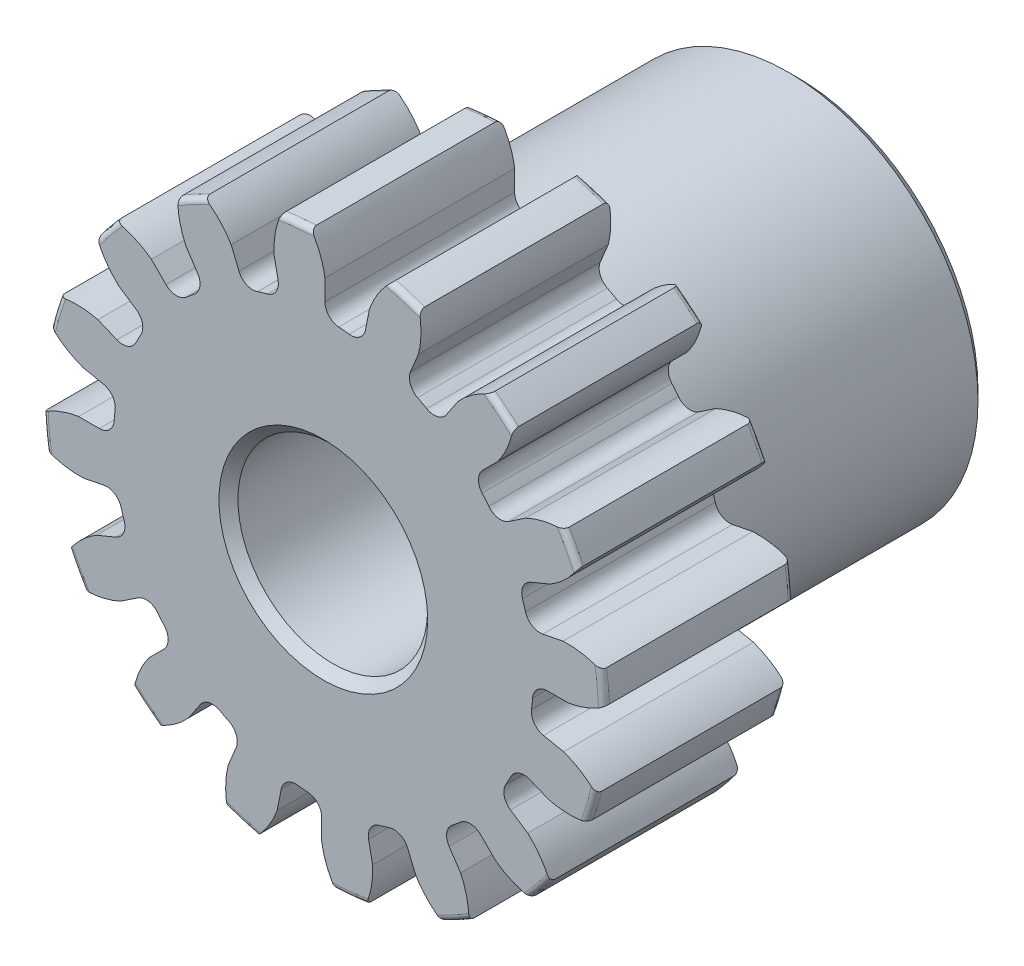
from build123d import *

# Parameters (mm, degrees)
SKETCH1_R                = 4.699
BOSS_EXTRUDE1_DEPTH      = 3.175
SKETCH2_W                = 4.7625
SKETCH2_H                = 3.175
FILLET2_R                = 0.09398
CUT_EXTRUDE1_DEPTH       = 8.9375
FILLET1_R                = 0.249115136
CIRPATTERN1_COUNT        = 16
FILLET1_OF_CIRPATTERN1_R = 0.249115136
SKETCH5_R                = 1.5875
CUT_EXTRUDE2_DEPTH       = 8.9375
CHAMFER1_SIZE            = 0.15875


with BuildPart() as part:
    # Sketch1 → Boss-Extrude1 (new body)
    with BuildSketch(Plane.XY):
        Circle(SKETCH1_R)
    extrude(amount=-BOSS_EXTRUDE1_DEPTH)

    # Sketch2 → Revolve1 (revolve)
    with BuildSketch(Plane(origin=(0, 0, 0), x_dir=(0, 0, -1), z_dir=(1, 0, 0))):
        with Locations((5.55625, 1.5875)):
            Rectangle(SKETCH2_W, SKETCH2_H)
    revolve(axis=Axis((0, 0, -3.175), (0, 0, -1)))

    # Fillet2
    fillet2_edges = [part.edges().sort_by_distance(p)[0] for p in [
        (-4.699, 0, 0),
        (-4.699, 0, -3.175),
        (0, -3.175, -3.175),
    ]]
    fillet(fillet2_edges, radius=FILLET2_R)

    # Sketch4 → Cut-Extrude1 (cut, through all)
    with BuildSketch(Plane.XY):
        with BuildLine():
            Line((0.026374273, 4.094308239), (0.026374273, 3.509466523))
            ThreePointArc((0.026374273, 3.509466523), (0.343998388, 3.492666028), (0.658797038, 3.44717817))
            Line((0.658797038, 3.44717817), (0.77289426, 4.020782265))
            add(Edge.make_bspline(
                [(1.393714491, 4.780251058), (0.938924727, 4.486466491), (0.77289426, 4.020782265)],
                knots=[0, 0, 0, 1, 1, 1], degree=2))
            ThreePointArc((1.393714491, 4.780251058), (0.488056032, 4.955304387), (-0.434351662, 4.960300283))
            add(Edge.make_bspline(
                [(-0.434351662, 4.960300283), (-0.045615255, 4.583435444), (0.026374273, 4.094308239)],
                knots=[0, 0, 0, 1, 1, 1], degree=2))
        make_face()
    cut_extrude1 = extrude(amount=-CUT_EXTRUDE1_DEPTH, mode=Mode.SUBTRACT)

    # Fillet1
    fillet1_edges = [part.edges().sort_by_distance(p)[0] for p in [
        (0.658797038, 3.44717817, -1.5875),
        (0.026374273, 3.509466523, -1.5875),
    ]]
    fillet(fillet1_edges, radius=FILLET1_R)

    # CirPattern1: Cut-Extrude1 ×16 about axis
    cirpattern1_axis = Axis((0, 0, -3.175), (0, 0, 1))
    for i in range(1, CIRPATTERN1_COUNT):
        add(cut_extrude1.rotate(cirpattern1_axis, i * 360 / CIRPATTERN1_COUNT), mode=Mode.SUBTRACT)

    # Fillet1 of CirPattern1
    fillet1_of_cirpattern1_edges = [part.edges().sort_by_distance(p)[0] for p in [
        (-0.710528875, 3.436888068, -1.5875),
        (-1.318648044, 3.252417288, -1.5875),
        (-1.971683207, 2.903362913, -1.5875),
        (-2.462918149, 2.500217004, -1.5875),
        (-2.932666645, 1.927827074, -1.5875),
        (-3.232231293, 1.367381346, -1.5875),
        (-3.44717817, 0.658797038, -1.5875),
        (-3.509466523, 0.026374273, -1.5875),
        (-3.436888068, -0.710528875, -1.5875),
        (-3.252417288, -1.318648044, -1.5875),
        (-2.903362913, -1.971683207, -1.5875),
        (-2.500217004, -2.462918149, -1.5875),
        (-1.927827074, -2.932666645, -1.5875),
        (-1.367381346, -3.232231293, -1.5875),
        (-0.658797038, -3.44717817, -1.5875),
        (-0.026374273, -3.509466523, -1.5875),
        (0.710528875, -3.436888068, -1.5875),
        (1.318648044, -3.252417288, -1.5875),
        (1.971683207, -2.903362913, -1.5875),
        (2.462918149, -2.500217004, -1.5875),
        (2.932666645, -1.927827074, -1.5875),
        (3.232231293, -1.367381346, -1.5875),
        (3.44717817, -0.658797038, -1.5875),
        (3.509466523, -0.026374273, -1.5875),
        (3.436888068, 0.710528875, -1.5875),
        (3.252417288, 1.318648044, -1.5875),
        (2.903362913, 1.971683207, -1.5875),
        (2.500217004, 2.462918149, -1.5875),
        (1.927827074, 2.932666645, -1.5875),
        (1.367381346, 3.232231293, -1.5875),
    ]]
    fillet(fillet1_of_cirpattern1_edges, radius=FILLET1_OF_CIRPATTERN1_R)

    # Sketch5 → Cut-Extrude2 (cut, through all)
    with BuildSketch(Plane.XY):
        Circle(SKETCH5_R)
    extrude(amount=-CUT_EXTRUDE2_DEPTH, mode=Mode.SUBTRACT)

    # Chamfer1
    chamfer1_edges = [part.edges().sort_by_distance(p)[0] for p in [
        (0, -3.175, -7.9375),
        (-1.5875, 0, -7.9375),
        (-1.5875, 0, 0),
    ]]
    chamfer(chamfer1_edges, length=CHAMFER1_SIZE)


solid = part.part
